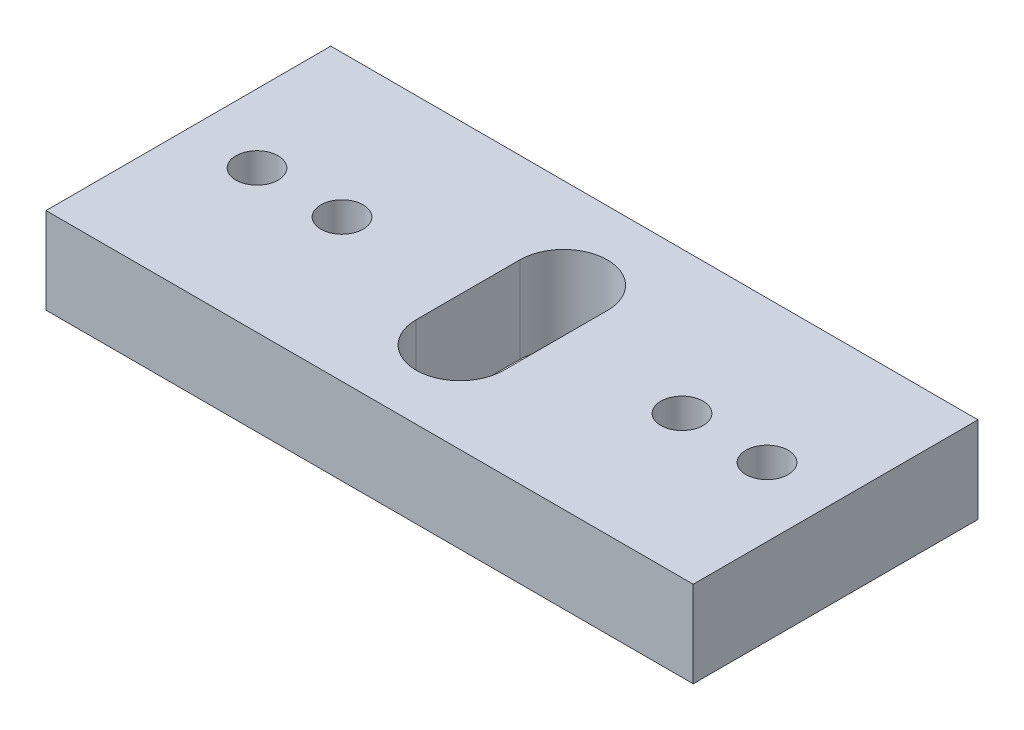
from build123d import *

# Parameters (mm, degrees)
SKETCH1_W           = 38.1
SKETCH1_H           = 16.764
SKETCH1_R           = 1.2446
BOSS_EXTRUDE1_DEPTH = 5.08


with BuildPart() as part:
    # Sketch1 → Boss-Extrude1 (new body)
    with BuildSketch(Plane(origin=(0, 0, 0), x_dir=(1, 0, 0), z_dir=(0, 1, 0))):
        Rectangle(SKETCH1_W, SKETCH1_H)
        with Locations((-10.0076, 0)):
            Circle(SKETCH1_R, mode=Mode.SUBTRACT)
        with Locations((-15.0114, 0)):
            Circle(SKETCH1_R, mode=Mode.SUBTRACT)
        with Locations((15.0114, 0)):
            Circle(SKETCH1_R, mode=Mode.SUBTRACT)
        with Locations((10.0076, 0)):
            Circle(SKETCH1_R, mode=Mode.SUBTRACT)
        with BuildLine():
            Line((2.568575, -3.048), (2.568575, 3.048))
            ThreePointArc((2.568575, 3.048), (-0.0111125, 5.6276875), (-2.5908, 3.048))
            Line((-2.5908, 3.048), (-2.5908, -3.048))
            ThreePointArc((-2.5908, -3.048), (-0.0111125, -5.6276875), (2.568575, -3.048))
        make_face(mode=Mode.SUBTRACT)
    extrude(amount=BOSS_EXTRUDE1_DEPTH)


solid = part.part
